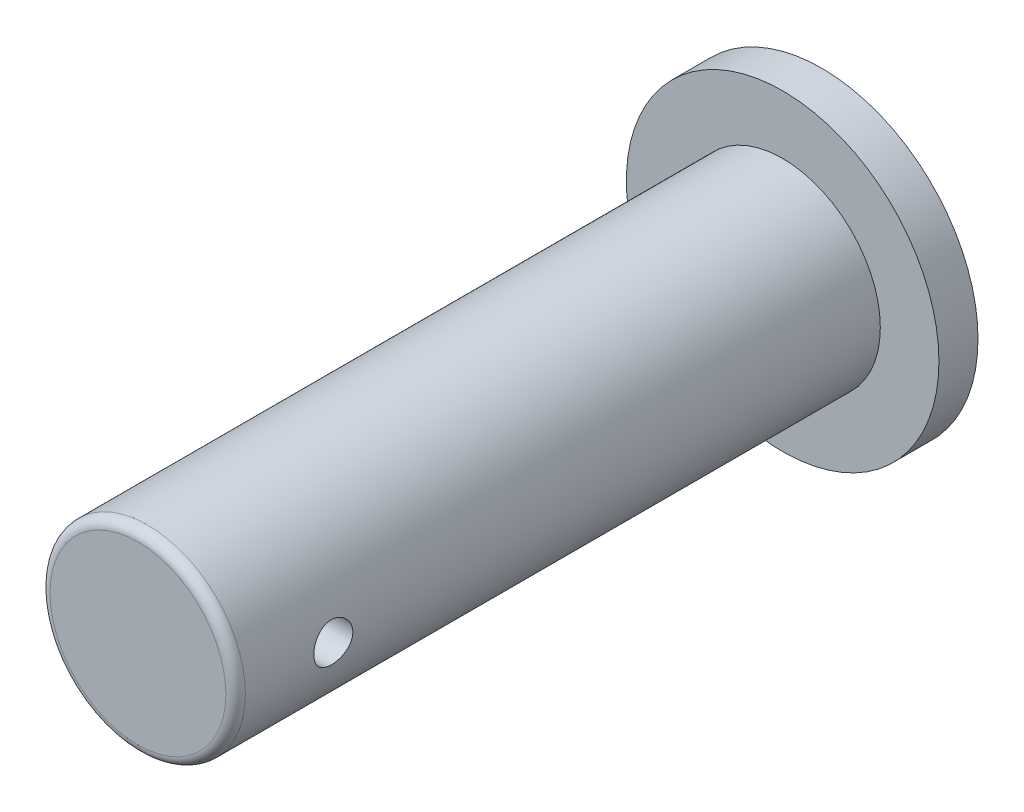
from build123d import *

# Parameters (mm, degrees)
SKETCH1_R               = 5
BOSS_EXTRUDE1_DEPTH     = 35
SKETCH1_3_R             = 8
SKETCH1_3_R_2           = 5
BOSS_EXTRUDE2_DEPTH     = 2
CUT_EXTRUDE3_DEPTH      = 37.783148315
CUT_EXTRUDE3_DEPTH_BACK = 37.783148315
SKETCH3_R               = 1
FILLET1_R               = 0.5


with BuildPart() as part:
    # Sketch1 → Boss-Extrude1 (new body)
    with BuildSketch(Plane.XY):
        Circle(SKETCH1_R)
    extrude(amount=BOSS_EXTRUDE1_DEPTH)

    # Sketch1_3 → Boss-Extrude2 (add)
    with BuildSketch(Plane.XY):
        Circle(SKETCH1_3_R)
        Circle(SKETCH1_3_R_2, mode=Mode.SUBTRACT)
    extrude(amount=BOSS_EXTRUDE2_DEPTH)

    # Sketch3 → Cut-Extrude3 (cut, two sides: drawn at the far end of the back side and taken through both)
    with BuildSketch(Plane(origin=(0, 0, 0), x_dir=(0, 0, -1), z_dir=(1, 0, 0)).offset(-CUT_EXTRUDE3_DEPTH_BACK)):
        with Locations((-30, 0)):
            Circle(SKETCH3_R)
    extrude(amount=CUT_EXTRUDE3_DEPTH + CUT_EXTRUDE3_DEPTH_BACK, mode=Mode.SUBTRACT)

    # Fillet1
    fillet1_edges = [part.edges().sort_by_distance(p)[0] for p in [
        (-5, 0, 35),
    ]]
    fillet(fillet1_edges, radius=FILLET1_R)


solid = part.part
